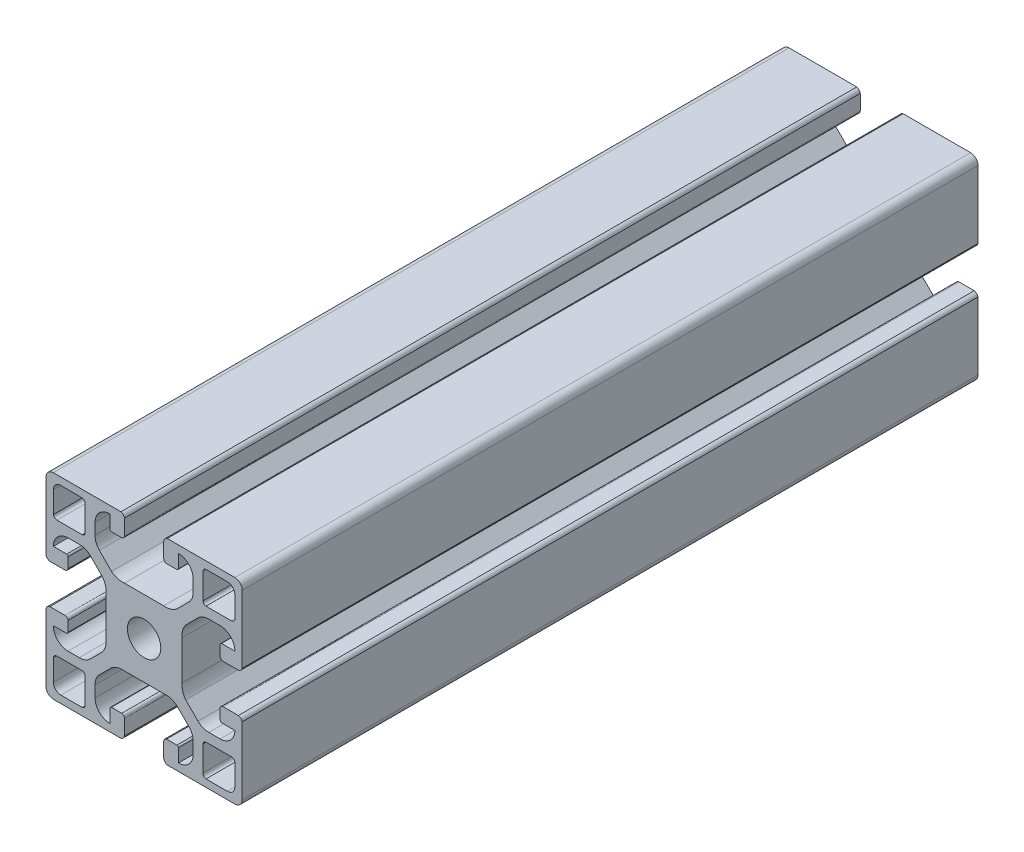
from build123d import *

# Parameters (mm, degrees)
CROQUIS1_R              = 3.4
SALIENTE_EXTRUIR1_DEPTH = 150


with BuildPart() as part:
    # Croquis1 → Saliente-Extruir1 (new body)
    with BuildSketch(Plane.XY):
        with BuildLine():
            ThreePointArc((1.5, 20), (0.439339828, 19.560660172), (0, 18.5))
            Line((0, 18.5), (0, 4.723246277))
            add(Edge.make_bspline(
                [(0, 4.723246277), (0.16818163, 4.15421854), (0.776519027, 4)],
                knots=[0, 0, 0, 1, 1, 1], degree=2))
            Line((0.776519027, 4), (3.876499959, 4))
            add(Edge.make_bspline(
                [(3.876499959, 4), (4.428343851, 4.075321958), (4.5, 4.561581647)],
                knots=[0, 0, 0, 0.770148696, 0.770148696, 0.770148696], degree=2))
            Line((4.5, 4.561581647), (4.5, 4.888433939))
            Line((4.5, 4.888433939), (4.5, 6.675480873))
            add(Edge.make_bspline(
                [(4.226708403, 7), (4.442584391, 6.908044465), (4.5, 6.675480873)],
                knots=[0, 0, 0, 1, 1, 1], degree=2))
            Line((4.226708403, 7), (1.5, 7))
            ThreePointArc((1.5, 7), (2.378679656, 9.121320344), (4.5, 10))
            Line((4.5, 10), (6.795713853, 10))
            add(Edge.make_bspline(
                [(6.795713853, 10), (6.864922078, 10.001348654), (6.933119616, 10)],
                knots=[0, 0, 0, 0.053884422, 0.053884422, 0.053884422], degree=2))
            add(Edge.make_bspline(
                [(6.933119616, 10), (8.130548293, 9.976320018), (9.016390221, 9.121082451)],
                knots=[0.053884422, 0.053884422, 0.053884422, 1, 1, 1], degree=2))
            Line((9.016390221, 9.121082451), (11.507582012, 6.629890661))
            add(Edge.make_bspline(
                [(11.507582012, 6.629890661), (12.156952743, 5.772287934), (12.25, 4.723246277)],
                knots=[0, 0, 0, 0.74933997, 0.74933997, 0.74933997], degree=2))
            add(Edge.make_bspline(
                [(12.25, 4.723246277), (12.281125029, 4.37233371), (12.25, 4)],
                knots=[0.74933997, 0.74933997, 0.74933997, 1, 1, 1], degree=2))
            Line((12.25, 4), (12.25, -4))
            add(Edge.make_bspline(
                [(12.25, -4.723246277), (12.281125029, -4.37233371), (12.25, -4)],
                knots=[0.74933997, 0.74933997, 0.74933997, 1, 1, 1], degree=2))
            add(Edge.make_bspline(
                [(11.507582012, -6.629890661), (12.156952743, -5.772287934), (12.25, -4.723246277)],
                knots=[0, 0, 0, 0.74933997, 0.74933997, 0.74933997], degree=2))
            Line((11.507582012, -6.629890661), (9.016390221, -9.121082451))
            add(Edge.make_bspline(
                [(6.933119616, -10), (8.130548293, -9.976320018), (9.016390221, -9.121082451)],
                knots=[0.053884422, 0.053884422, 0.053884422, 1, 1, 1], degree=2))
            add(Edge.make_bspline(
                [(6.795713853, -10), (6.864922078, -10.001348654), (6.933119616, -10)],
                knots=[0, 0, 0, 0.053884422, 0.053884422, 0.053884422], degree=2))
            Line((6.795713853, -10), (4.5, -10))
            ThreePointArc((4.5, -10), (2.378679656, -9.121320344), (1.5, -7))
            Line((1.5, -7), (4.226708403, -7))
            add(Edge.make_bspline(
                [(4.226708403, -7), (4.442584391, -6.908044465), (4.5, -6.675480873)],
                knots=[0, 0, 0, 1, 1, 1], degree=2))
            Line((4.5, -6.675480873), (4.5, -4.888433939))
            Line((4.5, -4.888433939), (4.5, -4.561581647))
            add(Edge.make_bspline(
                [(3.876499959, -4), (4.428343851, -4.075321958), (4.5, -4.561581647)],
                knots=[0, 0, 0, 0.770148696, 0.770148696, 0.770148696], degree=2))
            Line((3.876499959, -4), (0.776519027, -4))
            add(Edge.make_bspline(
                [(0, -4.723246277), (0.16818163, -4.15421854), (0.776519027, -4)],
                knots=[0, 0, 0, 1, 1, 1], degree=2))
            Line((0, -4.723246277), (0, -18.5))
            ThreePointArc((0, -18.5), (0.439339828, -19.560660172), (1.5, -20))
            Line((1.5, -20), (15.276753723, -20))
            add(Edge.make_bspline(
                [(15.276753723, -20), (15.84578146, -19.83181837), (16, -19.223480973)],
                knots=[0, 0, 0, 1, 1, 1], degree=2))
            Line((16, -19.223480973), (16, -16.123500041))
            add(Edge.make_bspline(
                [(16, -16.123500041), (15.924678042, -15.571656149), (15.438418353, -15.5)],
                knots=[0, 0, 0, 0.770148696, 0.770148696, 0.770148696], degree=2))
            Line((15.438418353, -15.5), (15.111566061, -15.5))
            Line((15.111566061, -15.5), (13.324519127, -15.5))
            add(Edge.make_bspline(
                [(13, -15.773291597), (13.091955535, -15.557415609), (13.324519127, -15.5)],
                knots=[0, 0, 0, 1, 1, 1], degree=2))
            Line((13, -15.773291597), (13, -18.5))
            ThreePointArc((13, -18.5), (10.878679656, -17.621320344), (10, -15.5))
            Line((10, -15.5), (10, -13.204286147))
            add(Edge.make_bspline(
                [(10, -13.204286147), (9.998651346, -13.135077922), (10, -13.066880384)],
                knots=[0, 0, 0, 0.053884422, 0.053884422, 0.053884422], degree=2))
            add(Edge.make_bspline(
                [(10, -13.066880384), (10.023679982, -11.869451707), (10.878917549, -10.983609779)],
                knots=[0.053884422, 0.053884422, 0.053884422, 1, 1, 1], degree=2))
            Line((10.878917549, -10.983609779), (13.370109339, -8.492417988))
            add(Edge.make_bspline(
                [(13.370109339, -8.492417988), (14.227712066, -7.843047257), (15.276753723, -7.75)],
                knots=[0, 0, 0, 0.74933997, 0.74933997, 0.74933997], degree=2))
            add(Edge.make_bspline(
                [(15.276753723, -7.75), (15.62766629, -7.718874971), (16, -7.75)],
                knots=[0.74933997, 0.74933997, 0.74933997, 1, 1, 1], degree=2))
            Line((16, -7.75), (24, -7.75))
            add(Edge.make_bspline(
                [(24.723246277, -7.75), (24.37233371, -7.718874971), (24, -7.75)],
                knots=[0.74933997, 0.74933997, 0.74933997, 1, 1, 1], degree=2))
            add(Edge.make_bspline(
                [(26.629890661, -8.492417988), (25.772287934, -7.843047257), (24.723246277, -7.75)],
                knots=[0, 0, 0, 0.74933997, 0.74933997, 0.74933997], degree=2))
            Line((26.629890661, -8.492417988), (29.121082451, -10.983609779))
            add(Edge.make_bspline(
                [(30, -13.066880384), (29.976320018, -11.869451707), (29.121082451, -10.983609779)],
                knots=[0.053884422, 0.053884422, 0.053884422, 1, 1, 1], degree=2))
            add(Edge.make_bspline(
                [(30, -13.204286147), (30.001348654, -13.135077922), (30, -13.066880384)],
                knots=[0, 0, 0, 0.053884422, 0.053884422, 0.053884422], degree=2))
            Line((30, -13.204286147), (30, -15.5))
            ThreePointArc((30, -15.5), (29.121320344, -17.621320344), (27, -18.5))
            Line((27, -18.5), (27, -15.773291597))
            add(Edge.make_bspline(
                [(27, -15.773291597), (26.908044465, -15.557415609), (26.675480873, -15.5)],
                knots=[0, 0, 0, 1, 1, 1], degree=2))
            Line((26.675480873, -15.5), (24.888433939, -15.5))
            Line((24.888433939, -15.5), (24.561581647, -15.5))
            add(Edge.make_bspline(
                [(24, -16.123500041), (24.075321958, -15.571656149), (24.561581647, -15.5)],
                knots=[0, 0, 0, 0.770148696, 0.770148696, 0.770148696], degree=2))
            Line((24, -16.123500041), (24, -19.223480973))
            add(Edge.make_bspline(
                [(24.723246277, -20), (24.15421854, -19.83181837), (24, -19.223480973)],
                knots=[0, 0, 0, 1, 1, 1], degree=2))
            Line((24.723246277, -20), (38.5, -20))
            ThreePointArc((38.5, -20), (39.560660172, -19.560660172), (40, -18.5))
            Line((40, -18.5), (40, -4.723246277))
            add(Edge.make_bspline(
                [(40, -4.723246277), (39.83181837, -4.15421854), (39.223480973, -4)],
                knots=[0, 0, 0, 1, 1, 1], degree=2))
            Line((39.223480973, -4), (36.123500041, -4))
            add(Edge.make_bspline(
                [(36.123500041, -4), (35.571656149, -4.075321958), (35.5, -4.561581647)],
                knots=[0, 0, 0, 0.770148696, 0.770148696, 0.770148696], degree=2))
            Line((35.5, -4.561581647), (35.5, -4.888433939))
            Line((35.5, -4.888433939), (35.5, -6.675480873))
            add(Edge.make_bspline(
                [(35.773291597, -7), (35.557415609, -6.908044465), (35.5, -6.675480873)],
                knots=[0, 0, 0, 1, 1, 1], degree=2))
            Line((35.773291597, -7), (38.5, -7))
            ThreePointArc((38.5, -7), (37.621320344, -9.121320344), (35.5, -10))
            Line((35.5, -10), (33.204286147, -10))
            add(Edge.make_bspline(
                [(33.204286147, -10), (33.135077922, -10.001348654), (33.066880384, -10)],
                knots=[0, 0, 0, 0.053884422, 0.053884422, 0.053884422], degree=2))
            add(Edge.make_bspline(
                [(33.066880384, -10), (31.869451707, -9.976320018), (30.983609779, -9.121082451)],
                knots=[0.053884422, 0.053884422, 0.053884422, 1, 1, 1], degree=2))
            Line((30.983609779, -9.121082451), (28.492417988, -6.629890661))
            add(Edge.make_bspline(
                [(28.492417988, -6.629890661), (27.843047257, -5.772287934), (27.75, -4.723246277)],
                knots=[0, 0, 0, 0.74933997, 0.74933997, 0.74933997], degree=2))
            add(Edge.make_bspline(
                [(27.75, -4.723246277), (27.718874971, -4.37233371), (27.75, -4)],
                knots=[0.74933997, 0.74933997, 0.74933997, 1, 1, 1], degree=2))
            Line((27.75, -4), (27.75, 4))
            add(Edge.make_bspline(
                [(27.75, 4.723246277), (27.718874971, 4.37233371), (27.75, 4)],
                knots=[0.74933997, 0.74933997, 0.74933997, 1, 1, 1], degree=2))
            add(Edge.make_bspline(
                [(28.492417988, 6.629890661), (27.843047257, 5.772287934), (27.75, 4.723246277)],
                knots=[0, 0, 0, 0.74933997, 0.74933997, 0.74933997], degree=2))
            Line((28.492417988, 6.629890661), (30.983609779, 9.121082451))
            add(Edge.make_bspline(
                [(33.066880384, 10), (31.869451707, 9.976320018), (30.983609779, 9.121082451)],
                knots=[0.053884422, 0.053884422, 0.053884422, 1, 1, 1], degree=2))
            add(Edge.make_bspline(
                [(33.204286147, 10), (33.135077922, 10.001348654), (33.066880384, 10)],
                knots=[0, 0, 0, 0.053884422, 0.053884422, 0.053884422], degree=2))
            Line((33.204286147, 10), (35.5, 10))
            ThreePointArc((35.5, 10), (37.621320344, 9.121320344), (38.5, 7))
            Line((38.5, 7), (35.773291597, 7))
            add(Edge.make_bspline(
                [(35.773291597, 7), (35.557415609, 6.908044465), (35.5, 6.675480873)],
                knots=[0, 0, 0, 1, 1, 1], degree=2))
            Line((35.5, 6.675480873), (35.5, 4.888433939))
            Line((35.5, 4.888433939), (35.5, 4.561581647))
            add(Edge.make_bspline(
                [(36.123500041, 4), (35.571656149, 4.075321958), (35.5, 4.561581647)],
                knots=[0, 0, 0, 0.770148696, 0.770148696, 0.770148696], degree=2))
            Line((36.123500041, 4), (39.223480973, 4))
            add(Edge.make_bspline(
                [(40, 4.723246277), (39.83181837, 4.15421854), (39.223480973, 4)],
                knots=[0, 0, 0, 1, 1, 1], degree=2))
            Line((40, 4.723246277), (40, 18.5))
            ThreePointArc((40, 18.5), (39.560660172, 19.560660172), (38.5, 20))
            Line((38.5, 20), (24.723246277, 20))
            add(Edge.make_bspline(
                [(24.723246277, 20), (24.15421854, 19.83181837), (24, 19.223480973)],
                knots=[0, 0, 0, 1, 1, 1], degree=2))
            Line((24, 19.223480973), (24, 16.123500041))
            add(Edge.make_bspline(
                [(24, 16.123500041), (24.075321958, 15.571656149), (24.561581647, 15.5)],
                knots=[0, 0, 0, 0.770148696, 0.770148696, 0.770148696], degree=2))
            Line((24.561581647, 15.5), (24.888433939, 15.5))
            Line((24.888433939, 15.5), (26.675480873, 15.5))
            add(Edge.make_bspline(
                [(27, 15.773291597), (26.908044465, 15.557415609), (26.675480873, 15.5)],
                knots=[0, 0, 0, 1, 1, 1], degree=2))
            Line((27, 15.773291597), (27, 18.5))
            ThreePointArc((27, 18.5), (29.121320344, 17.621320344), (30, 15.5))
            Line((30, 15.5), (30, 13.204286147))
            add(Edge.make_bspline(
                [(30, 13.204286147), (30.001348654, 13.135077922), (30, 13.066880384)],
                knots=[0, 0, 0, 0.053884422, 0.053884422, 0.053884422], degree=2))
            add(Edge.make_bspline(
                [(30, 13.066880384), (29.976320018, 11.869451707), (29.121082451, 10.983609779)],
                knots=[0.053884422, 0.053884422, 0.053884422, 1, 1, 1], degree=2))
            Line((29.121082451, 10.983609779), (26.629890661, 8.492417988))
            add(Edge.make_bspline(
                [(26.629890661, 8.492417988), (25.772287934, 7.843047257), (24.723246277, 7.75)],
                knots=[0, 0, 0, 0.74933997, 0.74933997, 0.74933997], degree=2))
            add(Edge.make_bspline(
                [(24.723246277, 7.75), (24.37233371, 7.718874971), (24, 7.75)],
                knots=[0.74933997, 0.74933997, 0.74933997, 1, 1, 1], degree=2))
            Line((24, 7.75), (16, 7.75))
            add(Edge.make_bspline(
                [(15.276753723, 7.75), (15.62766629, 7.718874971), (16, 7.75)],
                knots=[0.74933997, 0.74933997, 0.74933997, 1, 1, 1], degree=2))
            add(Edge.make_bspline(
                [(13.370109339, 8.492417988), (14.227712066, 7.843047257), (15.276753723, 7.75)],
                knots=[0, 0, 0, 0.74933997, 0.74933997, 0.74933997], degree=2))
            Line((13.370109339, 8.492417988), (10.878917549, 10.983609779))
            add(Edge.make_bspline(
                [(10, 13.066880384), (10.023679982, 11.869451707), (10.878917549, 10.983609779)],
                knots=[0.053884422, 0.053884422, 0.053884422, 1, 1, 1], degree=2))
            add(Edge.make_bspline(
                [(10, 13.204286147), (9.998651346, 13.135077922), (10, 13.066880384)],
                knots=[0, 0, 0, 0.053884422, 0.053884422, 0.053884422], degree=2))
            Line((10, 13.204286147), (10, 15.5))
            ThreePointArc((10, 15.5), (10.878679656, 17.621320344), (13, 18.5))
            Line((13, 18.5), (13, 15.773291597))
            add(Edge.make_bspline(
                [(13, 15.773291597), (13.091955535, 15.557415609), (13.324519127, 15.5)],
                knots=[0, 0, 0, 1, 1, 1], degree=2))
            Line((13.324519127, 15.5), (15.111566061, 15.5))
            Line((15.111566061, 15.5), (15.438418353, 15.5))
            add(Edge.make_bspline(
                [(16, 16.123500041), (15.924678042, 15.571656149), (15.438418353, 15.5)],
                knots=[0, 0, 0, 0.770148696, 0.770148696, 0.770148696], degree=2))
            Line((16, 16.123500041), (16, 19.223480973))
            add(Edge.make_bspline(
                [(15.276753723, 20), (15.84578146, 19.83181837), (16, 19.223480973)],
                knots=[0, 0, 0, 1, 1, 1], degree=2))
            Line((15.276753723, 20), (1.5, 20))
        make_face()
        with BuildLine():
            add(Edge.make_bspline(
                [(7.381658877, -18.5), (7.954867262, -18.386704516), (8, -17.770035709)],
                knots=[0, 0, 0, 1, 1, 1], degree=2))
            Line((7.381658877, -18.5), (3, -18.5))
            ThreePointArc((3, -18.5), (1.939339828, -18.060660172), (1.5, -17))
            Line((1.5, -17), (1.5, -12.618341123))
            add(Edge.make_bspline(
                [(1.5, -12.618341123), (1.613295484, -12.045132738), (2.229964291, -12)],
                knots=[0, 0, 0, 1, 1, 1], degree=2))
            Line((2.229964291, -12), (5.716559808, -12))
            Line((5.716559808, -12), (7.381658877, -12))
            add(Edge.make_bspline(
                [(7.381658877, -12), (7.910058331, -12.07521512), (8, -12.618341123)],
                knots=[0, 0, 0, 1, 1, 1], degree=2))
            Line((8, -12.618341123), (8, -14.283440192))
            Line((8, -14.283440192), (8, -17.770035709))
        make_face(mode=Mode.SUBTRACT)
        with BuildLine():
            Line((32.618341123, -12), (34.283440192, -12))
            Line((34.283440192, -12), (37.770035709, -12))
            add(Edge.make_bspline(
                [(38.5, -12.618341123), (38.386704516, -12.045132738), (37.770035709, -12)],
                knots=[0, 0, 0, 1, 1, 1], degree=2))
            Line((38.5, -12.618341123), (38.5, -17))
            ThreePointArc((38.5, -17), (38.060660172, -18.060660172), (37, -18.5))
            Line((37, -18.5), (32.618341123, -18.5))
            add(Edge.make_bspline(
                [(32.618341123, -18.5), (32.045132738, -18.386704516), (32, -17.770035709)],
                knots=[0, 0, 0, 1, 1, 1], degree=2))
            Line((32, -17.770035709), (32, -14.283440192))
            Line((32, -14.283440192), (32, -12.618341123))
            add(Edge.make_bspline(
                [(32.618341123, -12), (32.089941669, -12.07521512), (32, -12.618341123)],
                knots=[0, 0, 0, 1, 1, 1], degree=2))
        make_face(mode=Mode.SUBTRACT)
        with Locations((20, 0)):
            Circle(CROQUIS1_R, mode=Mode.SUBTRACT)
        with BuildLine():
            Line((7.381658877, 12), (5.716559808, 12))
            Line((5.716559808, 12), (2.229964291, 12))
            add(Edge.make_bspline(
                [(1.5, 12.618341123), (1.613295484, 12.045132738), (2.229964291, 12)],
                knots=[0, 0, 0, 1, 1, 1], degree=2))
            Line((1.5, 12.618341123), (1.5, 17))
            ThreePointArc((1.5, 17), (1.939339828, 18.060660172), (3, 18.5))
            Line((3, 18.5), (7.381658877, 18.5))
            add(Edge.make_bspline(
                [(7.381658877, 18.5), (7.954867262, 18.386704516), (8, 17.770035709)],
                knots=[0, 0, 0, 1, 1, 1], degree=2))
            Line((8, 17.770035709), (8, 14.283440192))
            Line((8, 14.283440192), (8, 12.618341123))
            add(Edge.make_bspline(
                [(7.381658877, 12), (7.910058331, 12.07521512), (8, 12.618341123)],
                knots=[0, 0, 0, 1, 1, 1], degree=2))
        make_face(mode=Mode.SUBTRACT)
        with BuildLine():
            add(Edge.make_bspline(
                [(32.618341123, 18.5), (32.045132738, 18.386704516), (32, 17.770035709)],
                knots=[0, 0, 0, 1, 1, 1], degree=2))
            Line((32.618341123, 18.5), (37, 18.5))
            ThreePointArc((37, 18.5), (38.060660172, 18.060660172), (38.5, 17))
            Line((38.5, 17), (38.5, 12.618341123))
            add(Edge.make_bspline(
                [(38.5, 12.618341123), (38.386704516, 12.045132738), (37.770035709, 12)],
                knots=[0, 0, 0, 1, 1, 1], degree=2))
            Line((37.770035709, 12), (34.283440192, 12))
            Line((34.283440192, 12), (32.618341123, 12))
            add(Edge.make_bspline(
                [(32.618341123, 12), (32.089941669, 12.07521512), (32, 12.618341123)],
                knots=[0, 0, 0, 1, 1, 1], degree=2))
            Line((32, 12.618341123), (32, 14.283440192))
            Line((32, 14.283440192), (32, 17.770035709))
        make_face(mode=Mode.SUBTRACT)
    extrude(amount=SALIENTE_EXTRUIR1_DEPTH)


solid = part.part
